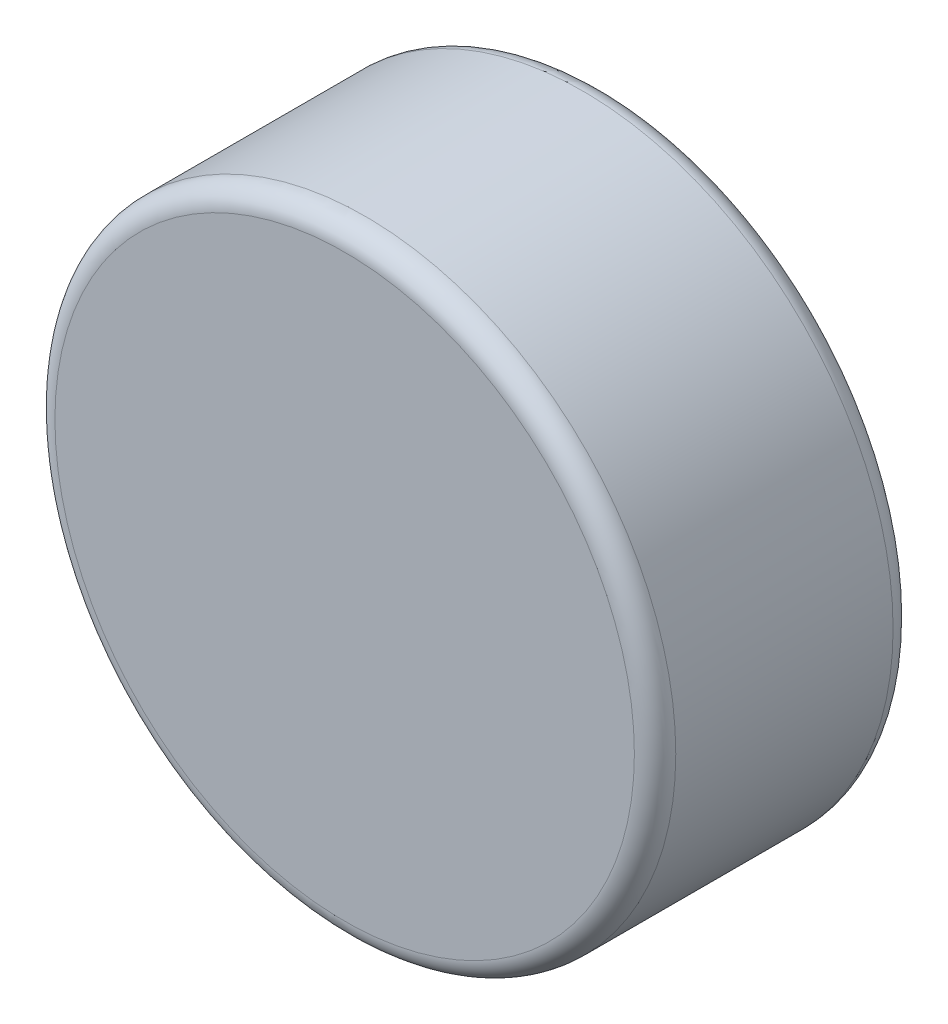
from build123d import *

# Parameters (mm, degrees)
SKETCH1_R           = 3
BOSS_EXTRUDE1_DEPTH = 2.5
FILLET1_R           = 0.2


with BuildPart() as part:
    # Sketch1 → Boss-Extrude1 (new body)
    with BuildSketch(Plane.XY):
        Circle(SKETCH1_R)
    extrude(amount=BOSS_EXTRUDE1_DEPTH)

    # Fillet1
    fillet1_edges = [part.edges().sort_by_distance(p)[0] for p in [
        (-3, 0, 0),
        (-3, 0, 2.5),
    ]]
    fillet(fillet1_edges, radius=FILLET1_R)


solid = part.part
